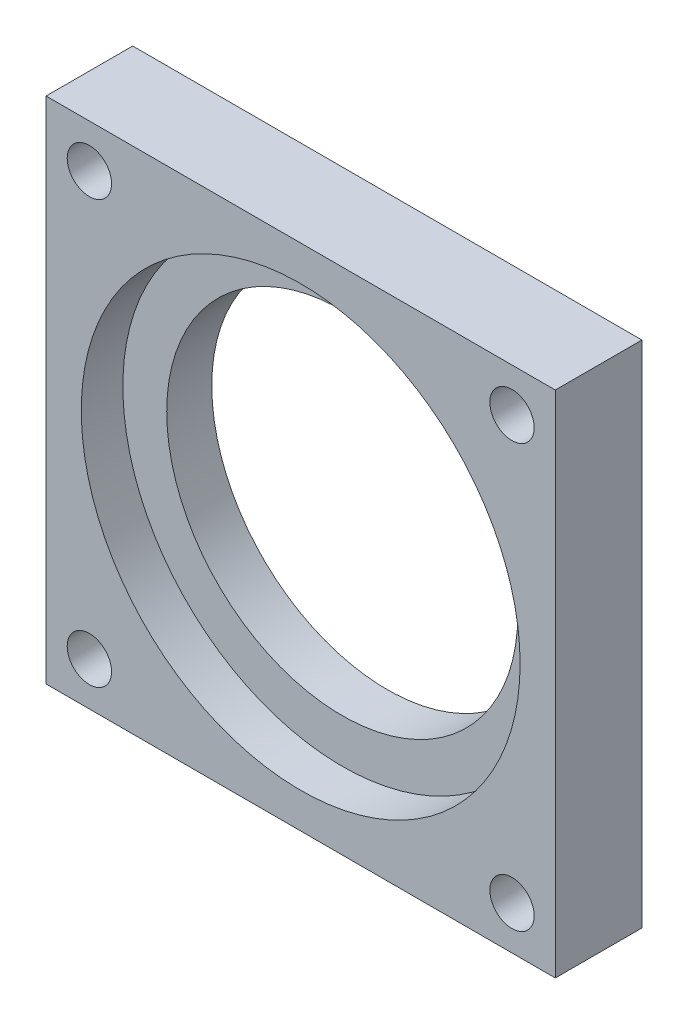
from build123d import *

# Parameters (mm, degrees)
SKETCH1_W                                      = 27.99999988
SKETCH1_H                                      = 28
BOSS_EXTRUDE1_DEPTH                            = 4.7625
SKETCH2_R                                      = 12.065
CUT_EXTRUDE1_DEPTH                             = 2.286
SKETCH3_R                                      = 9.652
CUT_EXTRUDE2_DEPTH                             = 3.4765
CSK_FOR_2_FLAT_HEAD_MACHINE_SCREW1_D           = 2.4384
CSK_FOR_2_FLAT_HEAD_MACHINE_SCREW1_CSINK_D     = 4.3688
CSK_FOR_2_FLAT_HEAD_MACHINE_SCREW1_CSINK_ANGLE = 82


with BuildPart() as part:
    # Sketch1 → Boss-Extrude1 (new body)
    with BuildSketch(Plane.XY):
        Rectangle(SKETCH1_W, SKETCH1_H)
    extrude(amount=BOSS_EXTRUDE1_DEPTH)

    # Sketch2 → Cut-Extrude1 (cut)
    with BuildSketch(Plane.XY.offset(4.7625)):
        Circle(SKETCH2_R)
    extrude(amount=-CUT_EXTRUDE1_DEPTH, mode=Mode.SUBTRACT)

    # Sketch3 → Cut-Extrude2 (cut, through all)
    with BuildSketch(Plane.XY.offset(2.4765)):
        Circle(SKETCH3_R)
    extrude(amount=-CUT_EXTRUDE2_DEPTH, mode=Mode.SUBTRACT)

    # CSK for #2 Flat Head Machine Screw1 (through all)
    with Locations(Plane(origin=(0, 0, 0), x_dir=(-1, 0, 0), z_dir=(0, 0, -1))):
        with Locations((11.61874994, 11.61875), (11.61874994, -11.61875), (-11.61874994, -11.61875), (-11.61874994, 11.61875)):
            CounterSinkHole(CSK_FOR_2_FLAT_HEAD_MACHINE_SCREW1_D / 2, CSK_FOR_2_FLAT_HEAD_MACHINE_SCREW1_CSINK_D / 2, counter_sink_angle=CSK_FOR_2_FLAT_HEAD_MACHINE_SCREW1_CSINK_ANGLE)


solid = part.part
